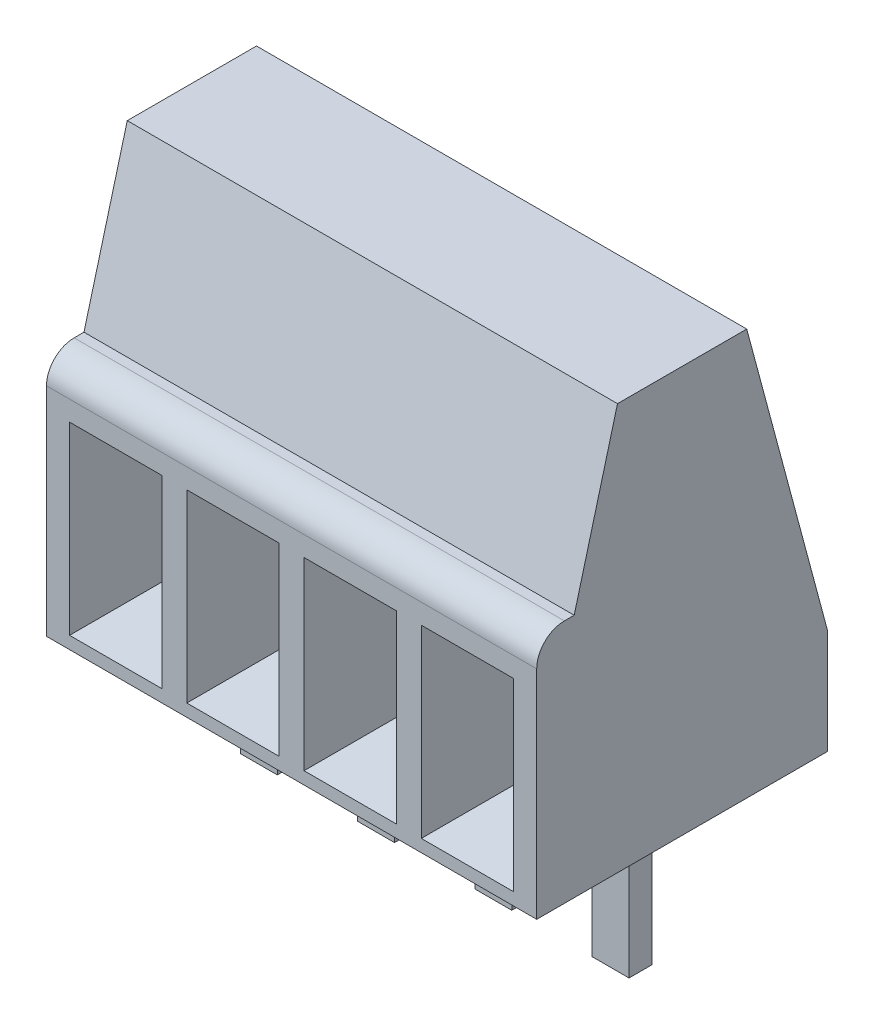
from build123d import *

# Parameters (mm, degrees)
SKETCH1_W           = 10.62
SKETCH1_H           = 6.3
BOSS_EXTRUDE1_DEPTH = 8.8
SKETCH2_W           = 0.8
SKETCH2_H           = 0.5
BOSS_EXTRUDE2_DEPTH = 3.2
CUT_EXTRUDE1_REACH  = 12.62
SKETCH4_W           = 2
SKETCH4_H           = 4
CUT_EXTRUDE2_DEPTH  = 3.15
CUT_EXTRUDE2_TAPER  = 10


with BuildPart() as part:
    # Sketch1 → Boss-Extrude1 (new body)
    with BuildSketch(Plane(origin=(0, 0, 0), x_dir=(1, 0, 0), z_dir=(0, 1, 0))):
        Rectangle(SKETCH1_W, SKETCH1_H)
    extrude(amount=BOSS_EXTRUDE1_DEPTH)

    # Sketch2 → Boss-Extrude2 (add)
    with BuildSketch(Plane(origin=(0, 0, 0), x_dir=(1, 0, 0), z_dir=(0, 1, 0))):
        with Locations((1.27, 0.2)):
            Rectangle(SKETCH2_W, SKETCH2_H)
        with Locations((3.81, 0.2)):
            Rectangle(SKETCH2_W, SKETCH2_H)
        with Locations((-1.27, 0.2)):
            Rectangle(SKETCH2_W, SKETCH2_H)
        with Locations((-3.81, 0.2)):
            Rectangle(SKETCH2_W, SKETCH2_H)
    extrude(amount=-BOSS_EXTRUDE2_DEPTH)

    # Sketch3 → Cut-Extrude1 (cut, up to next)
    with BuildSketch(Plane(origin=(5.31, 0, 0), x_dir=(0, 0, -1), z_dir=(1, 0, 0)), mode=Mode.PRIVATE) as cut_extrude1_sk1:
        with BuildLine():
            ThreePointArc((-3.15, 4.7), (-2.974264069, 5.124264069), (-2.55, 5.3))
            Line((-2.55, 5.3), (-2.337822174, 5.3))
            Line((-2.337822174, 5.3), (-1.4, 8.8))
            Line((-1.4, 8.8), (-3.15, 8.8))
            Line((-3.15, 8.8), (-3.15, 4.7))
        make_face()
    cut_extrude1_tool1 = extrude(cut_extrude1_sk1.sketch, amount=-CUT_EXTRUDE1_REACH, mode=Mode.PRIVATE) & part.part
    add(cut_extrude1_tool1.solids().sort_by_distance((5.31, 7.227986, 2.489914))[0], mode=Mode.SUBTRACT)
    # Sketch3 → Cut-Extrude1 (cut, up to next)
    with BuildSketch(Plane(origin=(5.31, 0, 0), x_dir=(0, 0, -1), z_dir=(1, 0, 0)), mode=Mode.PRIVATE) as cut_extrude1_sk2:
        Polygon((3.15, 8.8), (1.4, 8.8), (3.15, 2.268911087), align=None)
    cut_extrude1_tool2 = extrude(cut_extrude1_sk2.sketch, amount=-CUT_EXTRUDE1_REACH, mode=Mode.PRIVATE) & part.part
    add(cut_extrude1_tool2.solids().sort_by_distance((5.31, 6.62297, -2.566667))[0], mode=Mode.SUBTRACT)

    # Sketch4 → Cut-Extrude2 (cut)
    with BuildSketch(Plane.XY.offset(3.15)):
        with Locations((-3.81, 2.268911087)):
            Rectangle(SKETCH4_W, SKETCH4_H)
        with Locations((-1.27, 2.268911087)):
            Rectangle(SKETCH4_W, SKETCH4_H)
        with Locations((1.27, 2.268911087)):
            Rectangle(SKETCH4_W, SKETCH4_H)
        with Locations((3.81, 2.268911087)):
            Rectangle(SKETCH4_W, SKETCH4_H)
    extrude(amount=-CUT_EXTRUDE2_DEPTH, taper=CUT_EXTRUDE2_TAPER, mode=Mode.SUBTRACT)


solid = part.part
